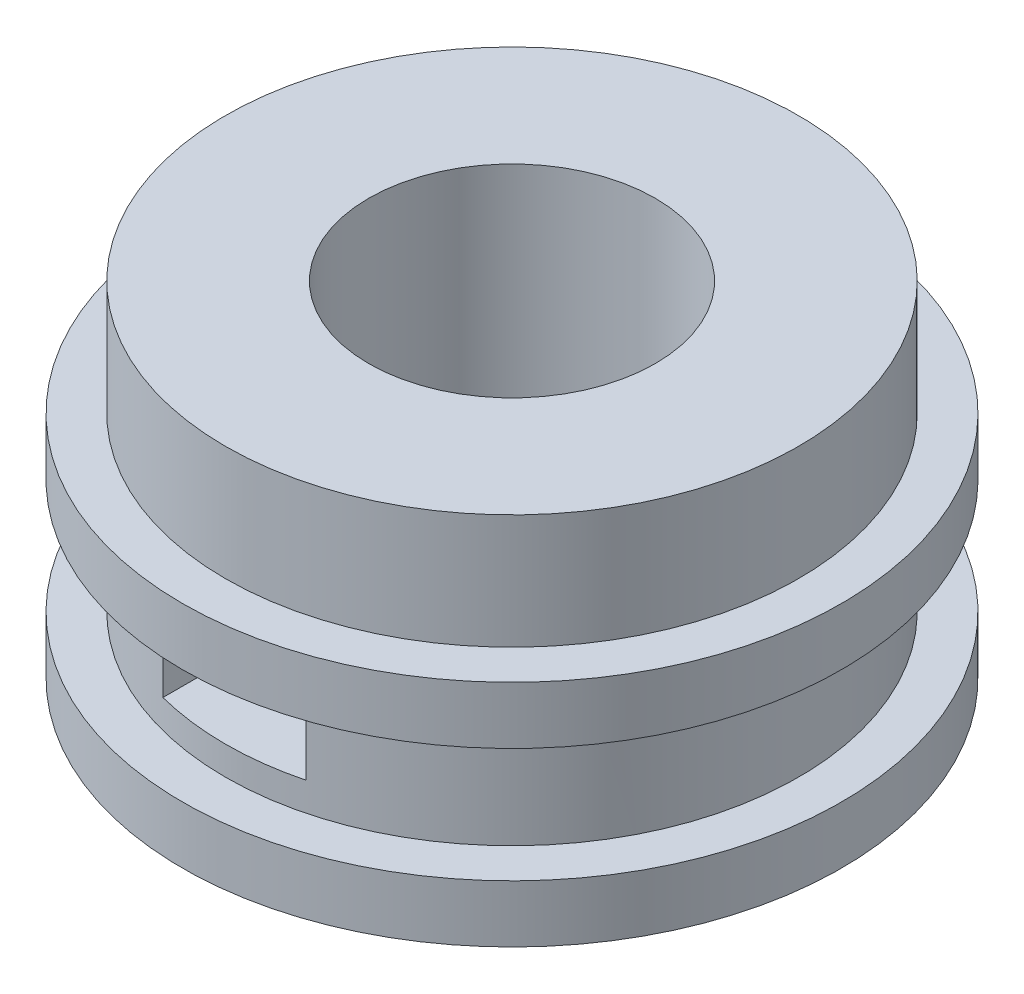
from build123d import *

# Parameters (mm, degrees)
SKETCH1_R                = 5
SKETCH1_R_2              = 2.5
BOSS_EXTRUDE1_DEPTH      = 4
BOSS_EXTRUDE1_DEPTH_BACK = 2
SKETCH2_W                = 2.5
SKETCH2_H                = 1
CUT_EXTRUDE1_DEPTH       = 6
CUT_EXTRUDE1_DEPTH_BACK  = 6
SKETCH3_R                = 5.75
SKETCH3_R_2              = 5
BOSS_EXTRUDE2_DEPTH      = 1
SKETCH5_R                = 5.75
SKETCH5_R_2              = 5
BOSS_EXTRUDE3_DEPTH      = 1


with BuildPart() as part:
    # Sketch1 → Boss-Extrude1 (new body, two sides)
    with BuildSketch(Plane(origin=(0, 0, 0), x_dir=(1, 0, 0), z_dir=(0, 1, 0))) as boss_extrude1_sk:
        Circle(SKETCH1_R)
        Circle(SKETCH1_R_2, mode=Mode.SUBTRACT)
    extrude(amount=BOSS_EXTRUDE1_DEPTH)
    extrude(boss_extrude1_sk.sketch, amount=-BOSS_EXTRUDE1_DEPTH_BACK)

    # Sketch2 → Cut-Extrude1 (cut, two sides)
    with BuildSketch(Plane.XY) as cut_extrude1_sk:
        Rectangle(SKETCH2_W, SKETCH2_H)
    extrude(amount=CUT_EXTRUDE1_DEPTH, mode=Mode.SUBTRACT)
    extrude(cut_extrude1_sk.sketch, amount=-CUT_EXTRUDE1_DEPTH_BACK, mode=Mode.SUBTRACT)

    # Sketch3 → Boss-Extrude2 (add)
    with BuildSketch(Plane.XZ.offset(2)):
        Circle(SKETCH3_R)
        Circle(SKETCH3_R_2, mode=Mode.SUBTRACT)
    extrude(amount=-BOSS_EXTRUDE2_DEPTH)

    # Sketch5 → Boss-Extrude3 (add)
    with BuildSketch(Plane(origin=(0, 1, 0), x_dir=(1, 0, 0), z_dir=(0, 1, 0))):
        Circle(SKETCH5_R)
        Circle(SKETCH5_R_2, mode=Mode.SUBTRACT)
    extrude(amount=BOSS_EXTRUDE3_DEPTH)


solid = part.part
